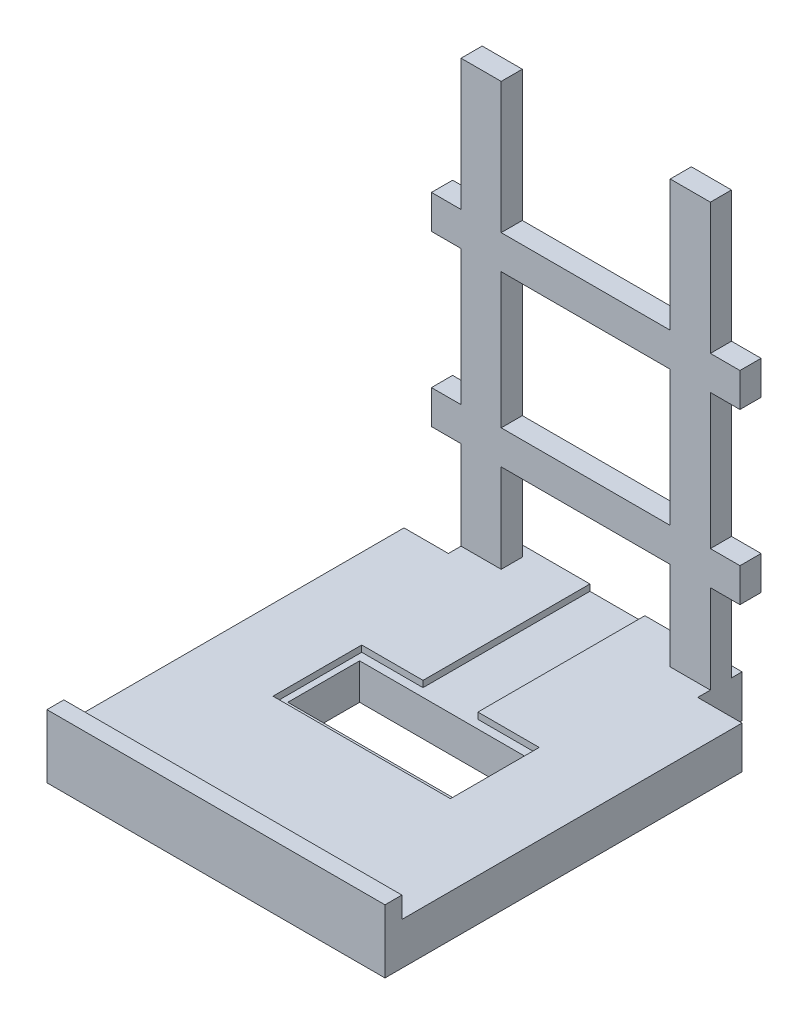
from build123d import *

# Parameters (mm, degrees)
SKETCH1_W           = 80
SKETCH1_H           = 95
BOSS_EXTRUDE1_DEPTH = 10
SKETCH2_W           = 10
SKETCH2_H           = 10
CUT_EXTRUDE1_DEPTH  = 10
SKETCH3_W           = 80
SKETCH3_H           = 5
BOSS_EXTRUDE2_DEPTH = 5
CUT_EXTRUDE2_DEPTH  = 1.5
SKETCH5_W           = 39
SKETCH5_H           = 17
CUT_EXTRUDE3_DEPTH  = 8.5
SKETCH6_W           = 9.5
SKETCH6_H           = 5
BOSS_EXTRUDE3_DEPTH = 100
SKETCH7_W           = 73
SKETCH7_H           = 8
BOSS_EXTRUDE4_DEPTH = 5
SKETCH8_W           = 80
SKETCH8_H           = 1
CUT_EXTRUDE4_DEPTH  = 5
CUT_EXTRUDE5_DEPTH  = 10


with BuildPart() as part:
    # Sketch1 → Boss-Extrude1 (new body)
    with BuildSketch(Plane(origin=(0, 0, 0), x_dir=(1, 0, 0), z_dir=(0, 1, 0))):
        Rectangle(SKETCH1_W, SKETCH1_H)
    extrude(amount=BOSS_EXTRUDE1_DEPTH)

    # Sketch2 → Cut-Extrude1 (cut)
    with BuildSketch(Plane(origin=(0, 10, 0), x_dir=(1, 0, 0), z_dir=(0, 1, 0))):
        with Locations((-35, 42.5)):
            Rectangle(SKETCH2_W, SKETCH2_H)
        with Locations((35, 42.5)):
            Rectangle(SKETCH2_W, SKETCH2_H)
    extrude(amount=-CUT_EXTRUDE1_DEPTH, mode=Mode.SUBTRACT)

    # Sketch3 → Boss-Extrude2 (add)
    with BuildSketch(Plane(origin=(0, 10, 0), x_dir=(1, 0, 0), z_dir=(0, 1, 0))):
        with Locations((0, -45)):
            Rectangle(SKETCH3_W, SKETCH3_H)
    extrude(amount=BOSS_EXTRUDE2_DEPTH)

    # Sketch4 → Cut-Extrude2 (cut)
    with BuildSketch(Plane(origin=(0, 10, 0), x_dir=(1, 0, 0), z_dir=(0, 1, 0))):
        Polygon((-21, -13), (21, -13), (21, 8), (6.491381871, 8), (6.5, 47.5), (-6.5, 47.5), (-6.5, 8), (-21, 8), align=None)
    extrude(amount=-CUT_EXTRUDE2_DEPTH, mode=Mode.SUBTRACT)

    # Sketch5 → Cut-Extrude3 (cut)
    with BuildSketch(Plane(origin=(0, 8.5, 0), x_dir=(1, 0, 0), z_dir=(0, 1, 0))):
        with Locations((0, -2.5)):
            Rectangle(SKETCH5_W, SKETCH5_H)
    extrude(amount=-CUT_EXTRUDE3_DEPTH, mode=Mode.SUBTRACT)

    # Sketch6 → Boss-Extrude3 (add)
    with BuildSketch(Plane(origin=(0, 10, 0), x_dir=(1, 0, 0), z_dir=(0, 1, 0))):
        with Locations((-24.75, 42.5)):
            Rectangle(SKETCH6_W, SKETCH6_H)
        with Locations((24.75, 42.5)):
            Rectangle(SKETCH6_W, SKETCH6_H)
    extrude(amount=BOSS_EXTRUDE3_DEPTH)

    # Sketch7 → Boss-Extrude4 (add)
    with BuildSketch(Plane.XY.offset(-40)):
        with Locations((0, 35)):
            Rectangle(SKETCH7_W, SKETCH7_H)
        with Locations((0, 75)):
            Rectangle(SKETCH7_W, SKETCH7_H)
    extrude(amount=-BOSS_EXTRUDE4_DEPTH)

    # Sketch8 → Cut-Extrude4 (cut)
    with BuildSketch(Plane(origin=(0, 15, 0), x_dir=(1, 0, 0), z_dir=(0, 1, 0))):
        with Locations((0, -43)):
            Rectangle(SKETCH8_W, SKETCH8_H)
    extrude(amount=-CUT_EXTRUDE4_DEPTH, mode=Mode.SUBTRACT)

    # Sketch9 → Cut-Extrude5 (cut)
    with BuildSketch(Plane(origin=(0, 10, 0), x_dir=(1, 0, 0), z_dir=(0, 1, 0))):
        Polygon((30, 47.5), (29.5, 47.5), (29.5, 37), (40, 37), (40, 37.5), (30, 37.5), align=None)
        Polygon((-40, 37.5), (-30, 37.5), (-30, 47.5), (-29.5, 47.5), (-29.5, 37), (-40, 37), align=None)
    extrude(amount=-CUT_EXTRUDE5_DEPTH, mode=Mode.SUBTRACT)


solid = part.part
